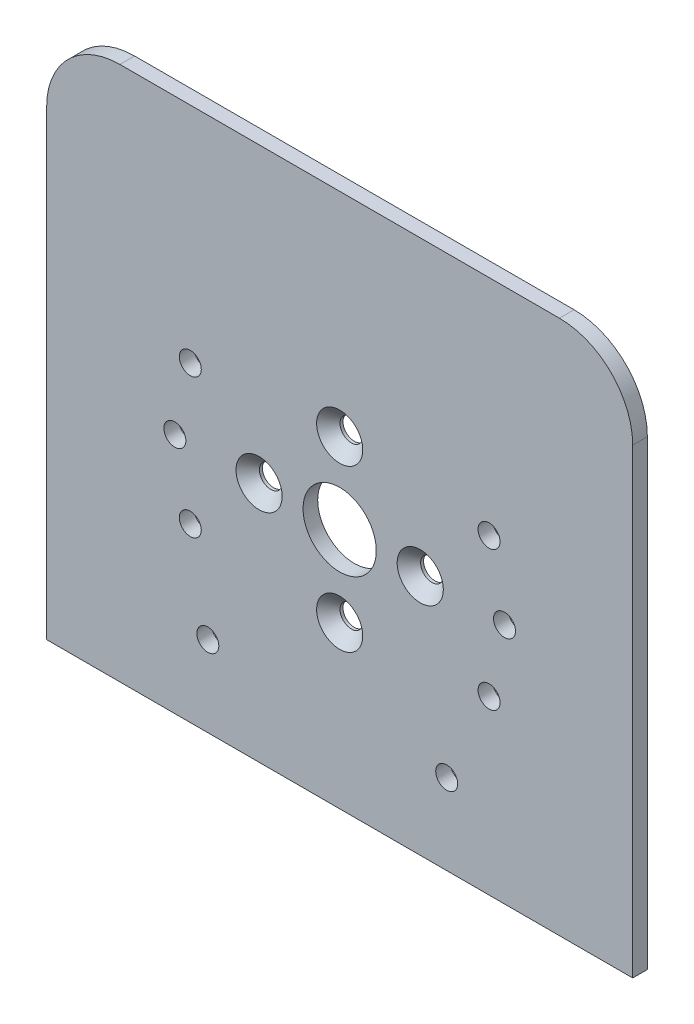
from build123d import *

# Parameters (mm, degrees)
SKETCH_1_W               = 80
SKETCH_1_H               = 73
SKETCH_1_R               = 5
EXTRUDE_1_DEPTH          = 2
PATTERN_CIRCULAR_1_COUNT = 4
FILLET_1_R               = 10
MM_TRANSITIONAL_1_D      = 3
MM_TRANSITIONAL_2_D      = 3


with BuildPart() as part:
    # 草图1 → 凸台-拉伸1 (new body)
    with BuildSketch(Plane(origin=(0, 0, -1.3), x_dir=(-1, 0, 0), z_dir=(0, 0, -1))):
        with Locations((0, 3.5)):
            Rectangle(SKETCH_1_W, SKETCH_1_H)
        Circle(SKETCH_1_R, mode=Mode.SUBTRACT)
    extrude(amount=EXTRUDE_1_DEPTH)

    # 草图3 → 打孔尺寸(%根据十字)槽沉头自攻螺钉的类型1 (revolve, cut)
    with BuildSketch(Plane(origin=(11, 0, -1.3), x_dir=(0, -1, 0), z_dir=(1, 0, 0))):
        Polygon((0, 0), (0, 5.431333959), (1.55, 4.5), (1.55, 1.6), (3.15, 0), align=None)
    hole_wizard_1 = revolve(axis=Axis((11, 0, 5.05), (0, 0, -1)), mode=Mode.SUBTRACT)

    # 阵列(圆周)1: 打孔尺寸(%根据十字)槽沉头自攻螺钉的类型1 ×4 about axis
    pattern_circular_1_axis = Axis((0, 0, 0), (0, 0, 1))
    for i in range(1, PATTERN_CIRCULAR_1_COUNT):
        add(hole_wizard_1.rotate(pattern_circular_1_axis, i * 360 / PATTERN_CIRCULAR_1_COUNT), mode=Mode.SUBTRACT)

    # 圆角1
    fillet_1_edges = [part.edges().sort_by_distance(p)[0] for p in [
        (40, 40, -2.3),
        (-40, 40, -2.3),
    ]]
    fillet(fillet_1_edges, radius=FILLET_1_R)

    # 大小mm Transitional 暗销孔1 (through all)
    with Locations(Plane(origin=(0, 0, -3.3), x_dir=(-1, 0, 0), z_dir=(0, 0, -1))):
        with Locations((-14.60943136, -22), (18, -22)):
            Hole(MM_TRANSITIONAL_1_D / 2)

    # 大小mm Transitional 暗销孔2 (through all)
    with Locations(Plane.XY.offset(-1.3)):
        with Locations((-20.391925208, -9.508910889), (-22.5, 0), (-20.391925208, 9.508910889), (20.391925208, -9.508910889), (22.5, 0), (20.391925208, 9.508910889)):
            Hole(MM_TRANSITIONAL_2_D / 2)


solid = part.part
